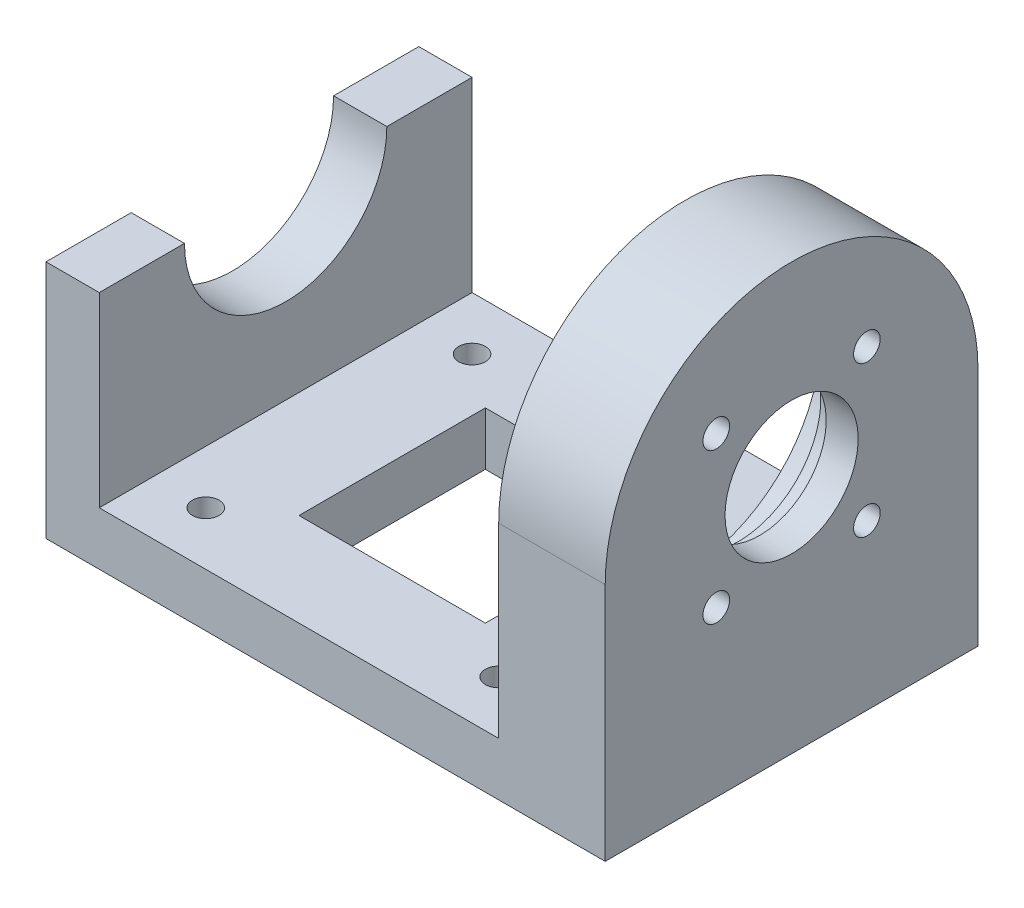
from build123d import *

# Parameters (mm, degrees)
SKETCH1_W           = 105
SKETCH1_H           = 70
BOSS_EXTRUDE1_DEPTH = 10
SKETCH2_W           = 20
SKETCH2_H           = 70
BOSS_EXTRUDE2_DEPTH = 70
CUT_EXTRUDE1_DEPTH  = 20
SKETCH4_R           = 25.5
CUT_EXTRUDE2_DEPTH  = 10
SKETCH5_R           = 15.5
CUT_EXTRUDE3_DEPTH  = 4
SKETCH7_R           = 2.5
CUT_EXTRUDE5_DEPTH  = 10
SKETCH9_W           = 10
SKETCH9_H           = 70
BOSS_EXTRUDE4_DEPTH = 35
SKETCH10_R          = 19
CUT_EXTRUDE7_DEPTH  = 10
SKETCH11_R          = 2.5
CUT_EXTRUDE9_DEPTH  = 10
SKETCH6_R           = 12.5
CUT_EXTRUDE10_DEPTH = 10
SKETCH13_W          = 35
SKETCH13_H          = 35
CUT_EXTRUDE11_DEPTH = 10


with BuildPart() as part:
    # Sketch1 → Boss-Extrude1 (new body)
    with BuildSketch(Plane(origin=(0, 0, 0), x_dir=(1, 0, 0), z_dir=(0, 1, 0))):
        Rectangle(SKETCH1_W, SKETCH1_H)
    extrude(amount=BOSS_EXTRUDE1_DEPTH)

    # Sketch2 → Boss-Extrude2 (add)
    with BuildSketch(Plane(origin=(0, 10, 0), x_dir=(1, 0, 0), z_dir=(0, 1, 0))):
        with Locations((42.5, 0)):
            Rectangle(SKETCH2_W, SKETCH2_H)
    extrude(amount=BOSS_EXTRUDE2_DEPTH)

    # Sketch3 → Cut-Extrude1 (cut)
    with BuildSketch(Plane.ZY.offset(-32.5)):
        with BuildLine():
            Line((3e-08, 80), (-35, 80))
            Line((-35, 80), (-35, 45))
            ThreePointArc((-35, 45), (-24.748737331, 69.748737352), (3e-08, 80))
        make_face()
        with BuildLine():
            Line((35, 80), (3e-08, 80))
            ThreePointArc((3e-08, 80), (24.748737352, 69.748737331), (35, 45))
            Line((35, 45), (35, 80))
        make_face()
    extrude(amount=-CUT_EXTRUDE1_DEPTH, mode=Mode.SUBTRACT)

    # Sketch4 → Cut-Extrude2 (cut)
    with BuildSketch(Plane.ZY.offset(-32.5)):
        with Locations((0, 45)):
            Circle(SKETCH4_R)
    extrude(amount=-CUT_EXTRUDE2_DEPTH, mode=Mode.SUBTRACT)

    # Sketch5 → Cut-Extrude3 (cut)
    with BuildSketch(Plane.ZY.offset(-42.5)):
        with Locations((0, 45)):
            Circle(SKETCH5_R)
    extrude(amount=-CUT_EXTRUDE3_DEPTH, mode=Mode.SUBTRACT)

    # Sketch7 → Cut-Extrude5 (cut)
    with BuildSketch(Plane.ZY.offset(-42.5)):
        with Locations((14.142135624, 59.142135624)):
            Circle(SKETCH7_R)
        with Locations((14.142135624, 30.857864376)):
            Circle(SKETCH7_R)
        with Locations((-14.142135624, 30.857864376)):
            Circle(SKETCH7_R)
        with Locations((-14.142135624, 59.142135624)):
            Circle(SKETCH7_R)
    extrude(amount=-CUT_EXTRUDE5_DEPTH, mode=Mode.SUBTRACT)

    # Sketch9 → Boss-Extrude4 (add)
    with BuildSketch(Plane(origin=(0, 10, 0), x_dir=(1, 0, 0), z_dir=(0, 1, 0))):
        with Locations((-47.5, 0)):
            Rectangle(SKETCH9_W, SKETCH9_H)
    extrude(amount=BOSS_EXTRUDE4_DEPTH)

    # Sketch10 → Cut-Extrude7 (cut)
    with BuildSketch(Plane.ZY.offset(52.5)):
        with Locations((0, 45)):
            Circle(SKETCH10_R)
    extrude(amount=-CUT_EXTRUDE7_DEPTH, mode=Mode.SUBTRACT)

    # Sketch11 → Cut-Extrude9 (cut)
    with BuildSketch(Plane(origin=(0, 10, 0), x_dir=(1, 0, 0), z_dir=(0, 1, 0))):
        with Locations((-32.5, 25)):
            Circle(SKETCH11_R)
        with Locations((22.5, 25)):
            Circle(SKETCH11_R)
        with Locations((22.5, -25)):
            Circle(SKETCH11_R)
        with Locations((-32.5, -25)):
            Circle(SKETCH11_R)
    extrude(amount=-CUT_EXTRUDE9_DEPTH, mode=Mode.SUBTRACT)

    # Sketch6 → Cut-Extrude10 (cut)
    with BuildSketch(Plane.ZY.offset(-46.5)):
        with Locations((0, 45)):
            Circle(SKETCH6_R)
    extrude(amount=-CUT_EXTRUDE10_DEPTH, mode=Mode.SUBTRACT)

    # Sketch13 → Cut-Extrude11 (cut)
    with BuildSketch(Plane(origin=(0, 10, 0), x_dir=(1, 0, 0), z_dir=(0, 1, 0))):
        with Locations((-5, 0)):
            Rectangle(SKETCH13_W, SKETCH13_H)
    extrude(amount=-CUT_EXTRUDE11_DEPTH, mode=Mode.SUBTRACT)


solid = part.part
